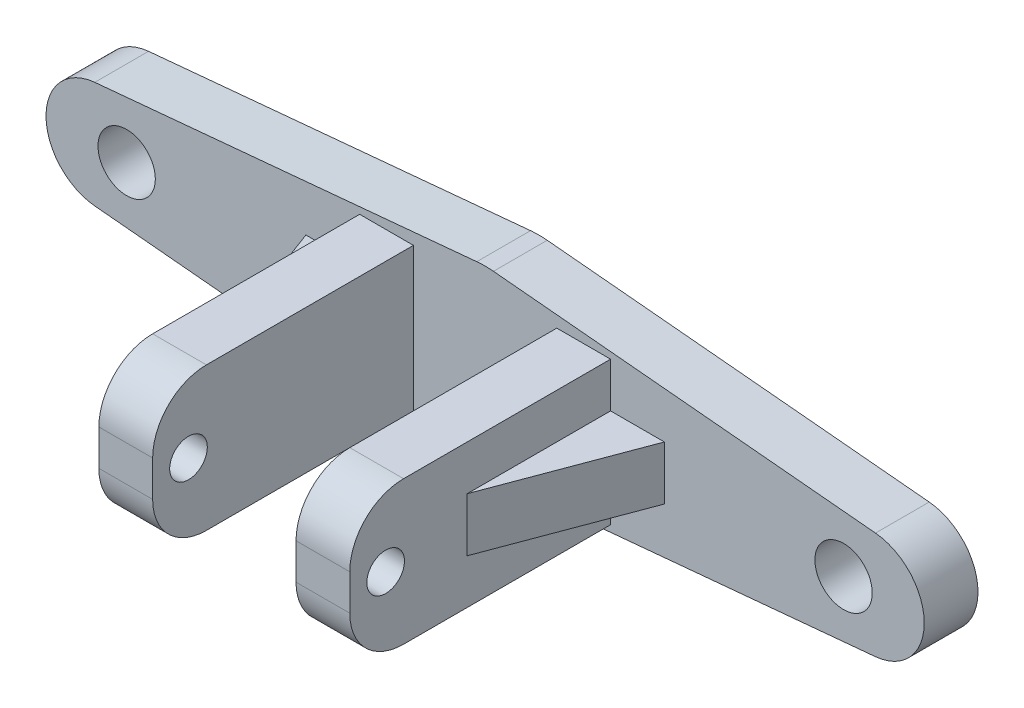
from build123d import *

# Parameters (mm, degrees)
EXTRUDE_1_DEPTH     = 3
SKETCH_2_R          = 1.6
CUT_EXTRUDE_1_DEPTH = 26.184320519
SKETCH_4_W          = 14
SKETCH_4_H          = 8
EXTRUDE_2_DEPTH     = 14.55
SKETCH_5_W          = 8
SKETCH_5_H          = 14.55
CUT_EXTRUDE_2_DEPTH = 32.452384647
SKETCH_6_R          = 1.05
CUT_EXTRUDE_3_DEPTH = 37.404017635
FILLET_1_R          = 3
RIB_1_REACH         = 32.549
SKETCH_7_WALL_W     = 71.642367062
SKETCH_7_WALL_H     = 3
RIB_2_REACH         = 32.549
SKETCH_8_WALL_W     = 71.642367062
SKETCH_8_WALL_H     = 3


with BuildPart() as part:
    # 草图1 → 凸台-拉伸1 (new body)
    with BuildSketch(Plane.XY):
        with BuildLine():
            Line((-21.779069767, 2.986991809), (-0.465116279, 4.978319681))
            ThreePointArc((-0.465116279, 4.978319681), (0, 5), (0.465116279, 4.978319681))
            Line((0.465116279, 4.978319681), (21.779069767, 2.986991809))
            ThreePointArc((21.779069767, 2.986991809), (24.5, 0), (21.779069767, -2.986991809))
            Line((21.779069767, -2.986991809), (0.465116279, -4.978319681))
            ThreePointArc((0.465116279, -4.978319681), (0, -5), (-0.465116279, -4.978319681))
            Line((-0.465116279, -4.978319681), (-21.779069767, -2.986991809))
            ThreePointArc((-21.779069767, -2.986991809), (-24.5, 0), (-21.779069767, 2.986991809))
        make_face()
    extrude(amount=EXTRUDE_1_DEPTH)

    # 草图2 → 切除-拉伸1 (cut, through all)
    with BuildSketch(Plane.XY.offset(3)):
        with Locations((-20, 0)):
            Circle(SKETCH_2_R)
        with Locations((20, 0)):
            Circle(SKETCH_2_R)
    extrude(amount=-CUT_EXTRUDE_1_DEPTH, mode=Mode.SUBTRACT)

    # 草图4 → 凸台-拉伸2 (add)
    with BuildSketch(Plane.XY.offset(3)):
        Rectangle(SKETCH_4_W, SKETCH_4_H)
    extrude(amount=EXTRUDE_2_DEPTH)

    # 草图5 → 切除-拉伸2 (cut, through all)
    with BuildSketch(Plane(origin=(0, 4, 0), x_dir=(1, 0, 0), z_dir=(0, 1, 0))):
        with Locations((0, -10.275)):
            Rectangle(SKETCH_5_W, SKETCH_5_H)
    extrude(amount=-CUT_EXTRUDE_2_DEPTH, mode=Mode.SUBTRACT)

    # 草图6 → 切除-拉伸3 (cut, through all)
    with BuildSketch(Plane(origin=(7, 0, 0), x_dir=(0, 0, -1), z_dir=(1, 0, 0))):
        with Locations((-15.55, 0)):
            Circle(SKETCH_6_R)
    extrude(amount=-CUT_EXTRUDE_3_DEPTH, mode=Mode.SUBTRACT)

    # 圆角1
    fillet_1_edges = [part.edges().sort_by_distance(p)[0] for p in [
        (-5.5, -4, 17.55),
        (5.5, 4, 17.55),
        (5.5, -4, 17.55),
        (-5.5, 4, 17.55),
    ]]
    fillet(fillet_1_edges, radius=FILLET_1_R)

    # 草图7 wall → 筋1 (add, up to next)
    with BuildSketch(Plane(origin=(8.5, 0, 7), x_dir=(-0.351123441588, 0, 0.936329177569), z_dir=(0.936329177569, 0, 0.351123441588)), mode=Mode.PRIVATE) as rib_1_sk1:
        Rectangle(SKETCH_7_WALL_W, SKETCH_7_WALL_H)
    rib_1_tool1 = extrude(rib_1_sk1.sketch, amount=-RIB_1_REACH, mode=Mode.PRIVATE) - part.part
    add(rib_1_tool1.solids().sort_by_distance((8.5, 0, 7))[0])

    # 草图8 wall → 筋2 (add, up to next)
    with BuildSketch(Plane(origin=(-8.5, 0, 7), x_dir=(0.351123441588, 0, 0.936329177569), z_dir=(0.936329177569, 0, -0.351123441588)), mode=Mode.PRIVATE) as rib_2_sk1:
        Rectangle(SKETCH_8_WALL_W, SKETCH_8_WALL_H)
    rib_2_tool1 = extrude(rib_2_sk1.sketch, amount=RIB_2_REACH, mode=Mode.PRIVATE) - part.part
    add(rib_2_tool1.solids().sort_by_distance((-8.5, 0, 7))[0])


solid = part.part
